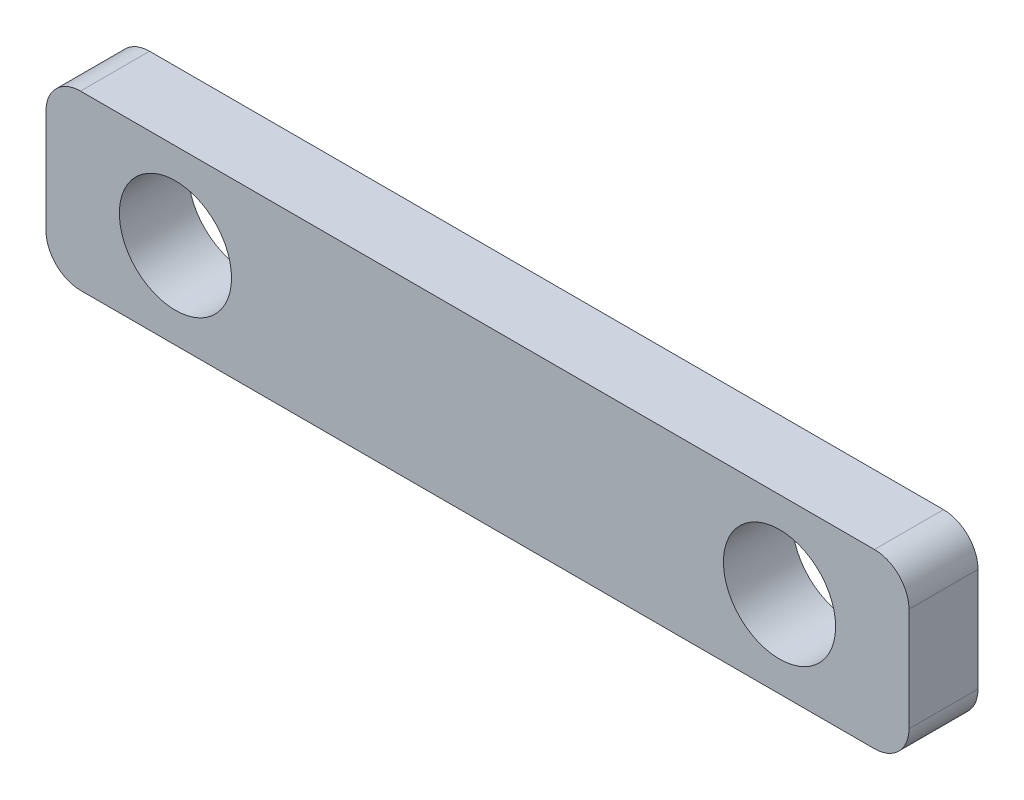
from build123d import *

# Parameters (mm, degrees)
ESQUISSE1_W        = 50
ESQUISSE1_H        = 10
ESQUISSE1_R        = 3.25
BOSS_EXTRU_1_DEPTH = 4
CONG_1_R           = 2


with BuildPart() as part:
    # Esquisse1 → Boss.-Extru.1 (new body)
    with BuildSketch(Plane.XY):
        Rectangle(ESQUISSE1_W, ESQUISSE1_H)
        with Locations((17.5, 0)):
            Circle(ESQUISSE1_R, mode=Mode.SUBTRACT)
        with Locations((-17.5, 0)):
            Circle(ESQUISSE1_R, mode=Mode.SUBTRACT)
    extrude(amount=BOSS_EXTRU_1_DEPTH)

    # Congé1
    cong_1_edges = [part.edges().sort_by_distance(p)[0] for p in [
        (-25, 5, 2),
        (25, 5, 2),
        (25, -5, 2),
        (-25, -5, 2),
    ]]
    fillet(cong_1_edges, radius=CONG_1_R)


solid = part.part
